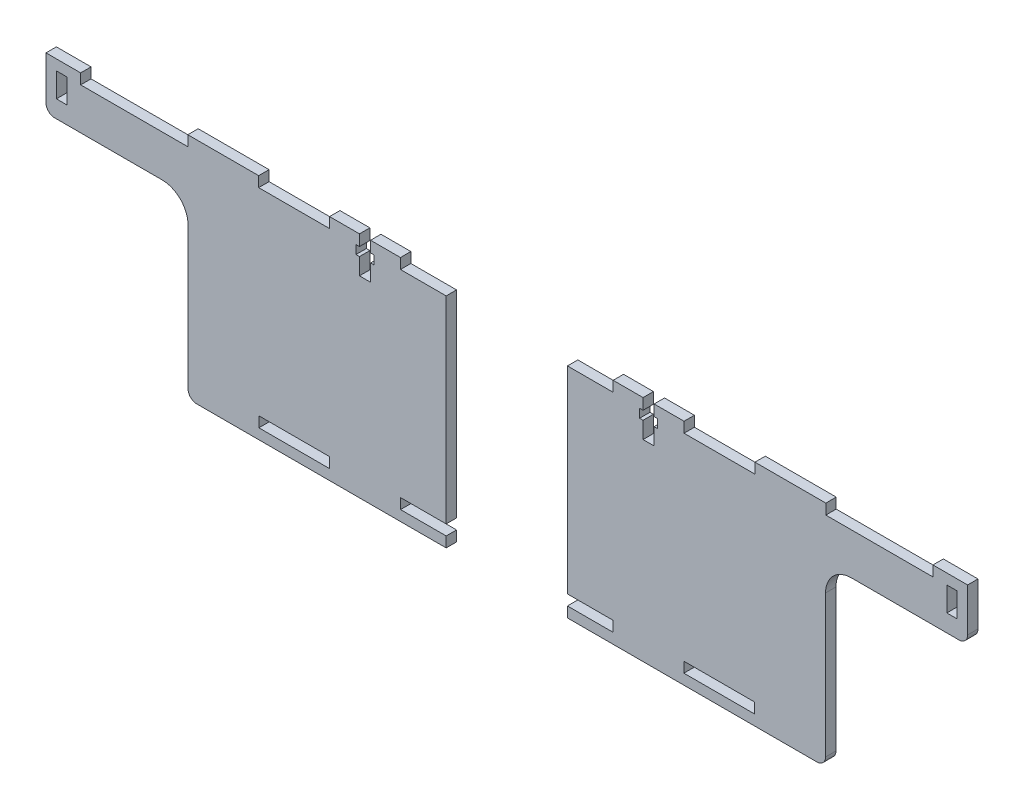
from build123d import *

# Parameters (mm, degrees)
BOSS_EXTRUDE1_DEPTH     = 3
SKETCH3_W               = 3
SKETCH3_H               = 7
SKETCH3_W_2             = 10.461538462
SKETCH3_H_2             = 3
SKETCH3_W_3             = 20.461538461
SKETCH3_W_4             = 20.444444445
CUT_EXTRUDE1_DEPTH      = 1
CUT_EXTRUDE1_DEPTH_BACK = 4
FILLET1_R               = 7.5
FILLET2_R               = 2.5
SKETCH4_W               = 3.2
SKETCH4_H               = 10.5
SKETCH4_W_2             = 5.2
SKETCH4_H_2             = 2.5
CUT_EXTRUDE2_DEPTH      = 1
CUT_EXTRUDE2_DEPTH_BACK = 4
SKETCH5_W               = 35
SKETCH5_H               = 66
CUT_EXTRUDE3_DEPTH      = 1
CUT_EXTRUDE3_DEPTH_BACK = 4


with BuildPart() as part:
    # Sketch2 → Boss-Extrude1 (new body)
    with BuildSketch(Plane.XY):
        Polygon((-133, 33), (133, 33), (133, 18), (92, 18), (92, -33), (-92, -33), (-92, 18), (-133, 18), align=None)
    extrude(amount=BOSS_EXTRUDE1_DEPTH)

    # Sketch3 → Cut-Extrude1 (cut, two sides)
    with BuildSketch(Plane.XY.offset(3)) as cut_extrude1_sk:
        with Locations((-128.5, 26.5)):
            Rectangle(SKETCH3_W, SKETCH3_H)
        with Locations((-117.769230769, 31.5)):
            Rectangle(SKETCH3_W_2, SKETCH3_H_2)
        with Locations((-102.307692308, 31.5)):
            Rectangle(SKETCH3_W_3, SKETCH3_H_2)
        with Locations((-61.384615385, 31.5)):
            Rectangle(SKETCH3_W_3, SKETCH3_H_2)
        with Locations((-20.461538462, 31.5)):
            Rectangle(SKETCH3_W_3, SKETCH3_H_2)
        with Locations((20.461538462, 31.5)):
            Rectangle(SKETCH3_W_3, SKETCH3_H_2)
        with Locations((61.384615385, 31.5)):
            Rectangle(SKETCH3_W_3, SKETCH3_H_2)
        with Locations((102.307692308, 31.5)):
            Rectangle(SKETCH3_W_3, SKETCH3_H_2)
        with Locations((117.769230769, 31.5)):
            Rectangle(SKETCH3_W_2, SKETCH3_H_2)
        with Locations((128.5, 26.5)):
            Rectangle(SKETCH3_W, SKETCH3_H)
        with Locations((-61.333333334, -28.5)):
            Rectangle(SKETCH3_W_4, SKETCH3_H_2)
        with Locations((-20.444444445, -28.5)):
            Rectangle(SKETCH3_W_4, SKETCH3_H_2)
        with Locations((20.444444445, -28.5)):
            Rectangle(SKETCH3_W_4, SKETCH3_H_2)
        with Locations((61.333333334, -28.5)):
            Rectangle(SKETCH3_W_4, SKETCH3_H_2)
    extrude(amount=CUT_EXTRUDE1_DEPTH, mode=Mode.SUBTRACT)
    extrude(cut_extrude1_sk.sketch, amount=-CUT_EXTRUDE1_DEPTH_BACK, mode=Mode.SUBTRACT)

    # Fillet1
    fillet1_edges = [part.edges().sort_by_distance(p)[0] for p in [
        (92, 18, 1.5),
        (-92, 18, 1.5),
    ]]
    fillet(fillet1_edges, radius=FILLET1_R)

    # Fillet2
    fillet2_edges = [part.edges().sort_by_distance(p)[0] for p in [
        (133, 18, 1.5),
        (92, -33, 1.5),
        (-92, -33, 1.5),
        (-133, 18, 1.5),
    ]]
    fillet(fillet2_edges, radius=FILLET2_R)

    # Sketch4 → Cut-Extrude2 (cut, two sides)
    with BuildSketch(Plane.XY.offset(3)) as cut_extrude2_sk:
        with Locations((-40.923076923, 27.75)):
            Rectangle(SKETCH4_W, SKETCH4_H)
        with Locations((40.923076923, 27.75)):
            Rectangle(SKETCH4_W, SKETCH4_H)
        with Locations((40.923076923, 28.575)):
            Rectangle(SKETCH4_W_2, SKETCH4_H_2)
        with Locations((-40.923076923, 28.575)):
            Rectangle(SKETCH4_W_2, SKETCH4_H_2)
    extrude(amount=CUT_EXTRUDE2_DEPTH, mode=Mode.SUBTRACT)
    extrude(cut_extrude2_sk.sketch, amount=-CUT_EXTRUDE2_DEPTH_BACK, mode=Mode.SUBTRACT)

    # Sketch5 → Cut-Extrude3 (cut, two sides)
    with BuildSketch(Plane.XY.offset(3)) as cut_extrude3_sk:
        Rectangle(SKETCH5_W, SKETCH5_H)
    extrude(amount=CUT_EXTRUDE3_DEPTH, mode=Mode.SUBTRACT)
    extrude(cut_extrude3_sk.sketch, amount=-CUT_EXTRUDE3_DEPTH_BACK, mode=Mode.SUBTRACT)


solid = part.part
